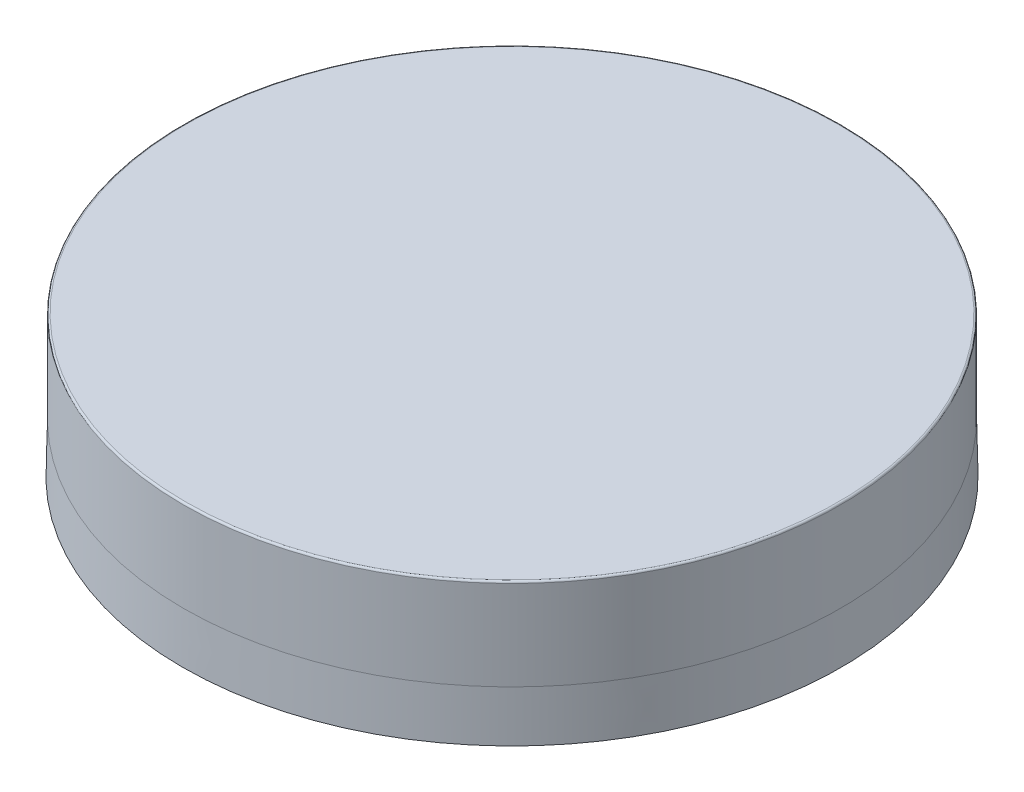
from build123d import *


with BuildPart() as part:
    # Sketch1 → Revolve1 (revolve)
    with BuildSketch(Plane.XY):
        with BuildLine():
            Line((0, 19.304), (-44.45, 19.304))
            ThreePointArc((-44.45, 19.304), (-44.629605122, 19.229605122), (-44.704, 19.05))
            Line((-44.704, 19.05), (-44.704, 6.858))
            Line((-44.704, 6.858), (-44.846875, 0))
            Line((-44.846875, 0), (-42.06875, 0))
            ThreePointArc((-42.06875, 0), (-41.399825713, 0.366456938), (-41.348556723, 1.127457516))
            Line((-41.348556723, 1.127457516), (-43.106443277, 4.921253029))
            ThreePointArc((-43.106443277, 4.921253029), (-43.161392721, 5.084101467), (-43.18, 5.254960545))
            Line((-43.18, 5.254960545), (-43.18, 8.09625))
            ThreePointArc((-43.18, 8.09625), (-42.947516008, 8.657516008), (-42.38625, 8.89))
            Line((-42.38625, 8.89), (-41.068625, 8.89))
            ThreePointArc((-41.068625, 8.89), (-40.362059456, 9.322081375), (-40.424738162, 10.147914628))
            Line((-40.424738162, 10.147914628), (-43.030136838, 13.762110576))
            ThreePointArc((-43.030136838, 13.762110576), (-43.141605625, 13.982396254), (-43.18, 14.226275204))
            Line((-43.18, 14.226275204), (-43.18, 17.526))
            ThreePointArc((-43.18, 17.526), (-43.105605122, 17.705605122), (-42.926, 17.78))
            Line((-42.926, 17.78), (0, 17.78))
            Line((0, 17.78), (0, 19.304))
        make_face()
    revolve(axis=Axis((0, 0, 0), (0, 1, 0)))


solid = part.part
